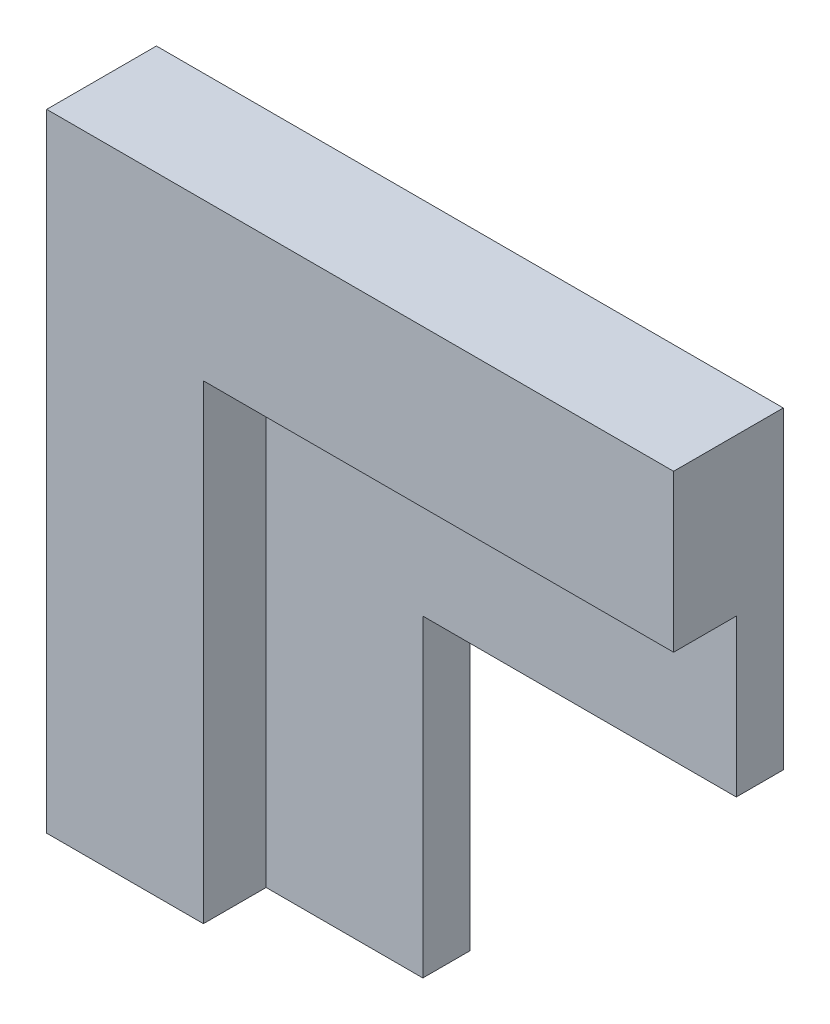
from build123d import *

# Parameters (mm, degrees)
BOSS_EXTRUDE2_DEPTH = 3
BOSS_EXTRUDE3_DEPTH = 4


with BuildPart() as part:
    # Sketch2 → Boss-Extrude2 (new body)
    with BuildSketch(Plane.XY):
        Polygon((0, 0), (0, -40), (20, -40), (20, -20), (40, -20), (40, 0), align=None)
    extrude(amount=BOSS_EXTRUDE2_DEPTH)

    # Sketch3 → Boss-Extrude3 (add)
    with BuildSketch(Plane.XY.offset(3)):
        Polygon((0, -40), (10, -40), (10, -10), (40, -10), (40, 0), (0, 0), align=None)
    extrude(amount=BOSS_EXTRUDE3_DEPTH)


solid = part.part
